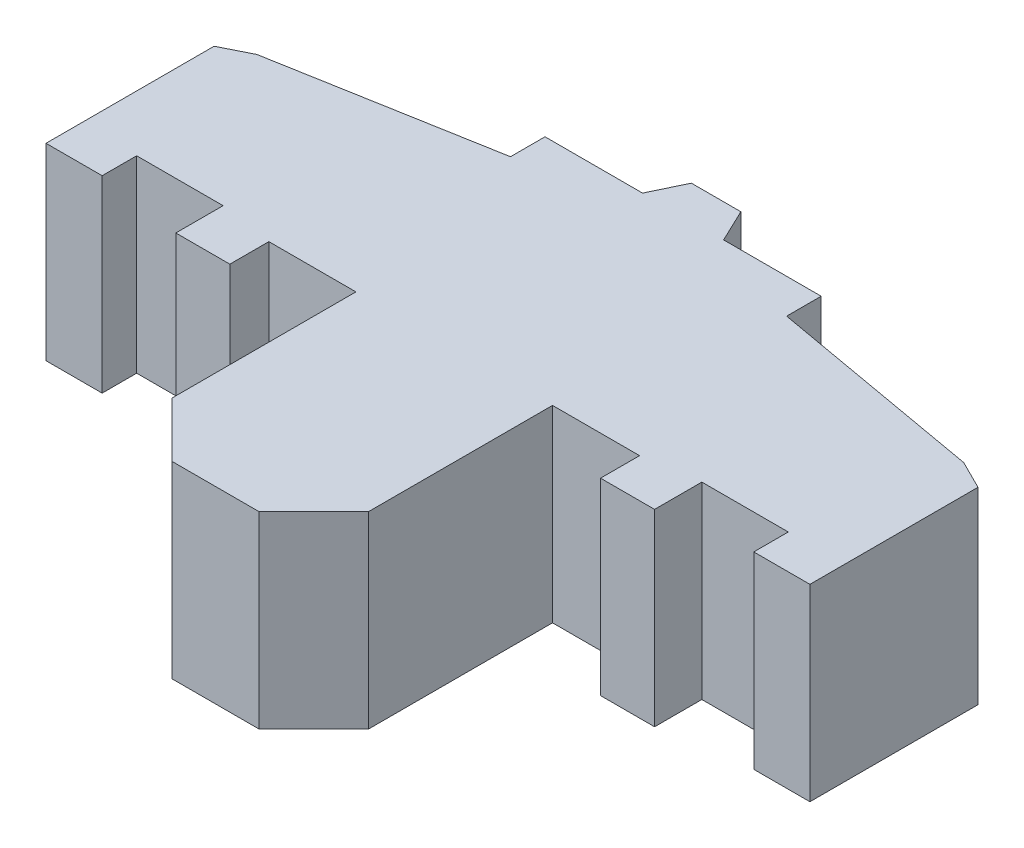
from build123d import *

# Parameters (mm, degrees)
BOSS_EXTRUDE1_DEPTH = 23


with BuildPart() as part:
    # Sketch1 → Boss-Extrude1 (new body)
    with BuildSketch(Plane(origin=(0, 0, 0), x_dir=(1, 0, 0), z_dir=(0, 1, 0))):
        Polygon((5.366336563, 43.198240053), (8.849047037, 44.93959529), (35.152676147, 49.613759348), (35.152676147, 53.829672027), (47.067211981, 53.829672027), (48.991867769, 57.862284156), (55.040785962, 57.862284156), (56.96544175, 53.829672027), (68.879977584, 53.829672027), (68.879977584, 49.613759348), (95.183606694, 44.93959529), (98.666317168, 43.198240053), (98.666317168, 22.668578308), (93.808852559, 22.668578308), (91.808852559, 22.668578308), (91.808852559, 26.884490988), (81.252764796, 26.884490988), (81.252764796, 21.110523622), (74.65394495, 21.110523622), (74.65394495, 25.876337956), (64.022512975, 25.876337956), (64.022512975, 3.422020423), (57.31833656, -3.282155992), (46.714317171, -3.282155992), (40.010140756, 3.422020423), (40.010140756, 25.876337956), (29.378708781, 25.876337956), (29.378708781, 21.110523622), (22.779888935, 21.110523622), (22.779888935, 26.884490988), (12.223801172, 26.884490988), (12.223801172, 22.668578308), (10.223801172, 22.668578308), (5.366336563, 22.668578308), align=None)
    extrude(amount=BOSS_EXTRUDE1_DEPTH)


solid = part.part
